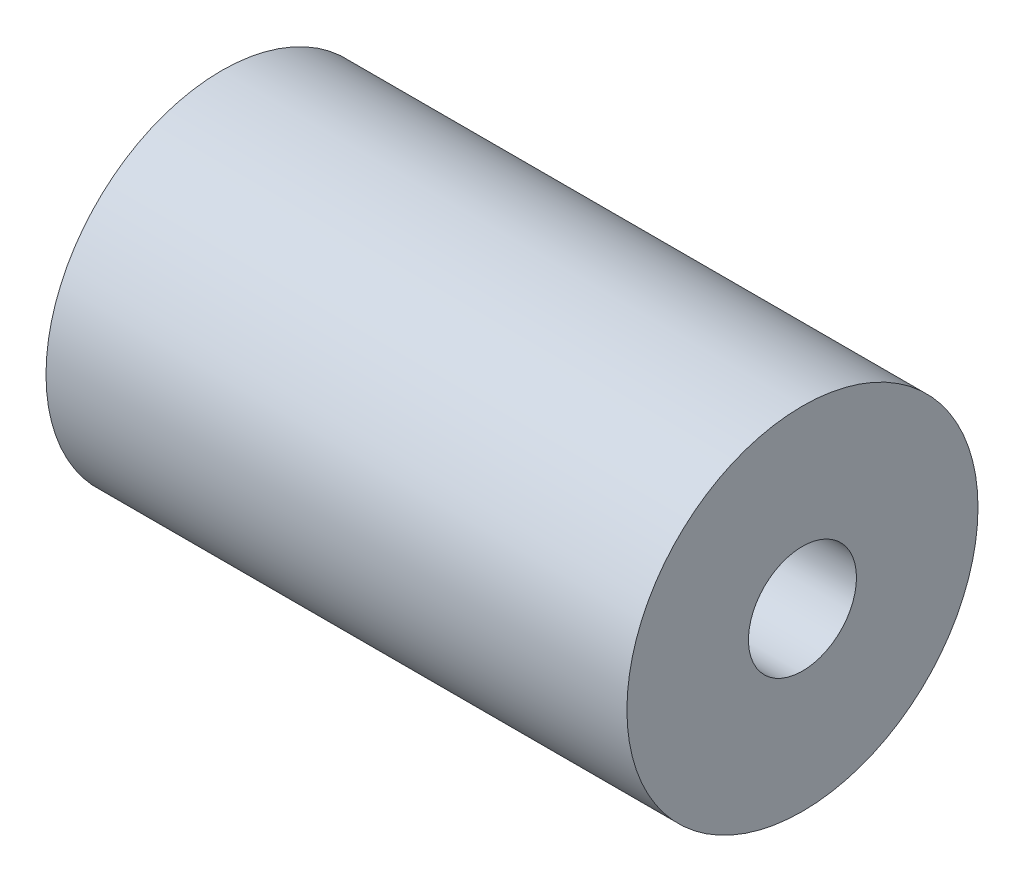
from build123d import *

# Parameters (mm, degrees)
SKETCH1_R           = 6.5
SKETCH1_R_2         = 2
BOSS_EXTRUDE1_DEPTH = 21.51


with BuildPart() as part:
    # Sketch1 → Boss-Extrude1 (new body)
    with BuildSketch(Plane(origin=(0, 0, 0), x_dir=(0, 0, -1), z_dir=(1, 0, 0))):
        Circle(SKETCH1_R)
        Circle(SKETCH1_R_2, mode=Mode.SUBTRACT)
    extrude(amount=BOSS_EXTRUDE1_DEPTH)


solid = part.part
